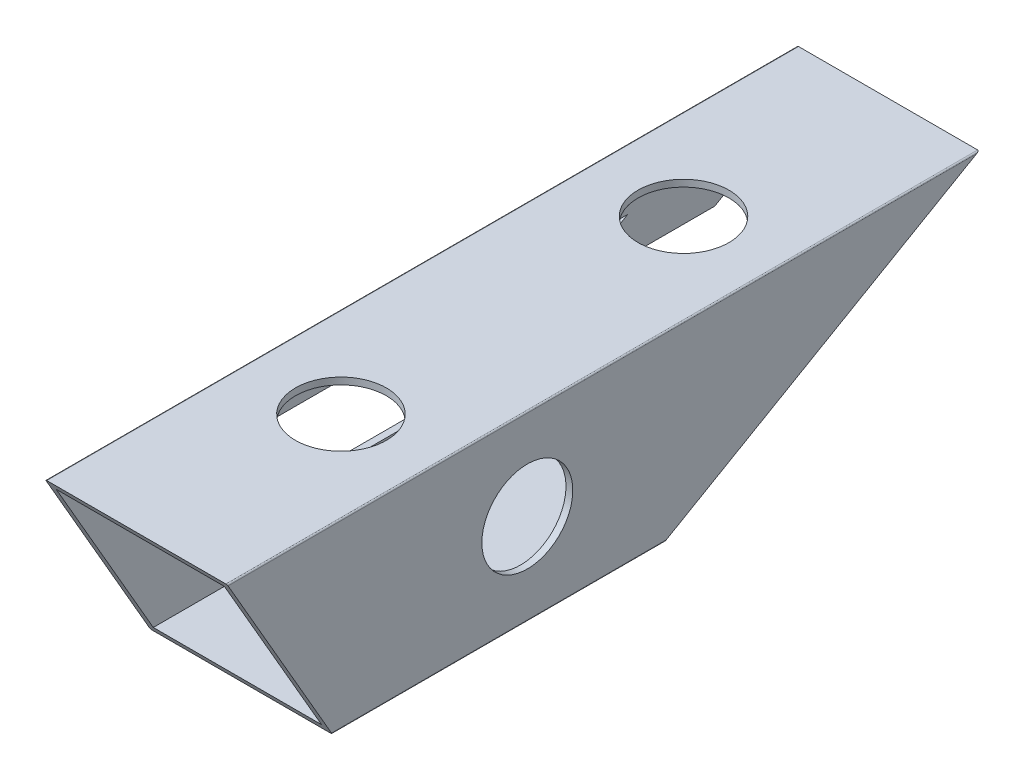
from build123d import *

# Parameters (mm, degrees)
SKETCH1_W           = 37
SKETCH1_H           = 37
BOSS_EXTRUDE1_DEPTH = 165.35
CUT_EXTRUDE1_DEPTH  = 50
BOSS_EXTRUDE2_START = -10
BOSS_EXTRUDE2_DEPTH = 20
BOSS_EXTRUDE3_DEPTH = 1.5
CUT_EXTRUDE2_DEPTH  = 10
SKETCH6_R           = 10
CUT_EXTRUDE3_DEPTH  = 10
SKETCH7_R           = 10
CUT_EXTRUDE4_DEPTH  = 10


with BuildPart() as part:
    # Sketch1 → Boss-Extrude1 (new body)
    with BuildSketch(Plane.XY):
        with BuildLine():
            Line((0.305025041, 0), (39.694974959, 0))
            ThreePointArc((39.694974959, 0), (39.910660234, 0.089339766), (40, 0.305025041))
            Line((40, 0.305025041), (40, 39.694974959))
            ThreePointArc((40, 39.694974959), (39.910660234, 39.910660234), (39.694974959, 40))
            Line((39.694974959, 40), (0.305025041, 40))
            ThreePointArc((0.305025041, 40), (0.089339766, 39.910660234), (0, 39.694974959))
            Line((0, 39.694974959), (0, 0.305025041))
            ThreePointArc((0, 0.305025041), (0.089339766, 0.089339766), (0.305025041, 0))
        make_face()
        with Locations((20, 20)):
            Rectangle(SKETCH1_W, SKETCH1_H, mode=Mode.SUBTRACT)
    extrude(amount=BOSS_EXTRUDE1_DEPTH)

    # Sketch2 → Cut-Extrude1 (cut)
    with BuildSketch(Plane(origin=(40, 0, 0), x_dir=(0, 0, -1), z_dir=(1, 0, 0))):
        Polygon((0, 40), (-69.282032303, 0), (0, 0), align=None)
        Polygon((-165.35, 40), (-142.255989232, 0), (-165.35, 0), align=None)
    extrude(amount=-CUT_EXTRUDE1_DEPTH, mode=Mode.SUBTRACT)

    # Sketch3 → Boss-Extrude2 (add)
    with BuildSketch(Plane.ZY.offset(BOSS_EXTRUDE2_START)):
        Polygon((69.282032303, 0), (52.282032303, 0), (52.282032303, 1.5), (66.683956091, 1.5), align=None)
    extrude(amount=-BOSS_EXTRUDE2_DEPTH)

    # Sketch4 → Boss-Extrude3 (add)
    with BuildSketch(Plane.ZY):
        Polygon((2.320508076, 30), (19.641016151, 20), (34.641016151, 20), (17.320508076, 30), align=None)
    extrude(amount=-BOSS_EXTRUDE3_DEPTH)

    # Sketch5 → Cut-Extrude2 (cut)
    with BuildSketch(Plane(origin=(0, 0, 0), x_dir=(0, 0, -1), z_dir=(1, 0, 0))):
        Polygon((-38.784609691, 28), (-66.497422612, 12), (-131.863684387, 12), (-141.101288694, 28), align=None)
    extrude(amount=CUT_EXTRUDE2_DEPTH, mode=Mode.SUBTRACT)

    # Sketch6 → Cut-Extrude3 (cut)
    with BuildSketch(Plane(origin=(0, 40, 0), x_dir=(1, 0, 0), z_dir=(0, 1, 0))):
        with Locations(Location((20, -120.35, 0), (0, 0, 180))):
            Circle(SKETCH6_R)
        with Locations(Location((20, -45, 0), (0, 0, 180))):
            Circle(SKETCH6_R)
    extrude(amount=-CUT_EXTRUDE3_DEPTH, mode=Mode.SUBTRACT)

    # Sketch7 → Cut-Extrude4 (cut)
    with BuildSketch(Plane.ZY.offset(-38.5)):
        with Locations((99.35, 20)):
            Circle(SKETCH7_R)
    extrude(amount=-CUT_EXTRUDE4_DEPTH, mode=Mode.SUBTRACT)


solid = part.part
